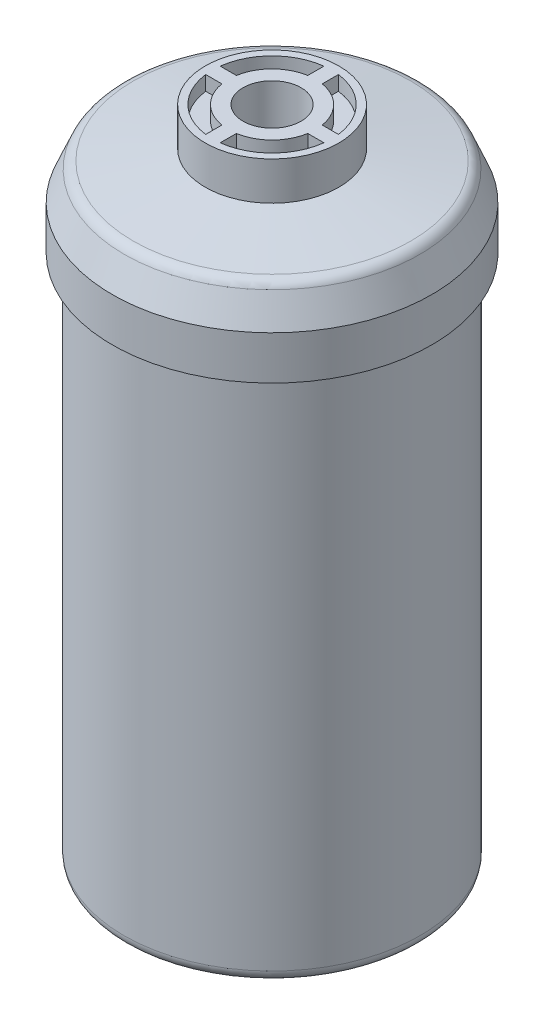
from build123d import *

# Parameters (mm, degrees)
CUT_EXTRUDE2_DEPTH = 3.175
CUT_EXTRUDE3_DEPTH = 3.175


with BuildPart() as part:
    # Sketch1 → Revolve1 (revolve)
    with BuildSketch(Plane.XY):
        with BuildLine():
            Line((6.35, 154.305), (14.605, 154.305))
            Line((14.605, 154.305), (14.605, 145.923))
            Line((14.605, 145.923), (30.329807741, 143.593398853))
            ThreePointArc((30.329807741, 143.593398853), (31.517982802, 143.084998901), (32.302189527, 142.057745136))
            Line((32.302189527, 142.057745136), (34.925, 135.763))
            Line((34.925, 135.763), (34.925, 126.238))
            Line((34.925, 126.238), (32.385, 124.968))
            Line((32.385, 124.968), (32.385, 13.12493032))
            ThreePointArc((32.385, 13.12493032), (31.763853046, 11.460717897), (30.204210245, 10.610458606))
            Line((30.204210245, 10.610458606), (14.605, 8.382))
            Line((14.605, 8.382), (14.605, 0))
            Line((14.605, 0), (6.35, 0))
            Line((6.35, 0), (6.35, 10.409948615))
            Line((6.35, 10.409948615), (29.21, 13.6756629))
            Line((29.21, 13.6756629), (29.21, 140.549643155))
            Line((29.21, 140.549643155), (6.35, 143.936309822))
            Line((6.35, 143.936309822), (6.35, 154.305))
        make_face()
    revolve(axis=Axis((0, 0, 0), (0, 1, 0)))

    # Sketch2 → Cut-Extrude2 (cut)
    with BuildSketch(Plane.XZ):
        with BuildLine():
            Line((1.5875, -12.920338618), (1.5875, -9.391776656))
            ThreePointArc((1.5875, -9.391776656), (6.735192091, -6.735192091), (9.391776656, -1.5875))
            Line((9.391776656, -1.5875), (12.920338618, -1.5875))
            ThreePointArc((12.920338618, -1.5875), (9.204762524, -9.204762524), (1.5875, -12.920338618))
        make_face()
        with BuildLine():
            Line((-1.5875, -12.920338618), (-1.5875, -9.391776656))
            ThreePointArc((-1.5875, -9.391776656), (-6.735192091, -6.735192091), (-9.391776656, -1.5875))
            Line((-9.391776656, -1.5875), (-12.920338618, -1.5875))
            ThreePointArc((-12.920338618, -1.5875), (-9.204762524, -9.204762524), (-1.5875, -12.920338618))
        make_face()
        with BuildLine():
            Line((-12.920338618, 1.5875), (-9.391776656, 1.5875))
            ThreePointArc((-9.391776656, 1.5875), (-6.735192091, 6.735192091), (-1.5875, 9.391776656))
            Line((-1.5875, 9.391776656), (-1.5875, 12.920338618))
            ThreePointArc((-1.5875, 12.920338618), (-9.204762524, 9.204762524), (-12.920338618, 1.5875))
        make_face()
        with BuildLine():
            Line((1.5875, 12.920338618), (1.5875, 9.391776656))
            ThreePointArc((1.5875, 9.391776656), (6.735192091, 6.735192091), (9.391776656, 1.5875))
            Line((9.391776656, 1.5875), (12.920338618, 1.5875))
            ThreePointArc((12.920338618, 1.5875), (9.204762524, 9.204762524), (1.5875, 12.920338618))
        make_face()
    extrude(amount=-CUT_EXTRUDE2_DEPTH, mode=Mode.SUBTRACT)

    # Sketch3 → Cut-Extrude3 (cut)
    with BuildSketch(Plane(origin=(0, 154.305, 0), x_dir=(-1, 0, 0), z_dir=(0, 1, 0))):
        with BuildLine():
            Line((1.5875, -12.920338618), (1.5875, -9.391776656))
            ThreePointArc((1.5875, -9.391776656), (6.735192091, -6.735192091), (9.391776656, -1.5875))
            Line((9.391776656, -1.5875), (12.920338618, -1.5875))
            ThreePointArc((12.920338618, -1.5875), (9.204762524, -9.204762524), (1.5875, -12.920338618))
        make_face()
        with BuildLine():
            Line((-1.5875, -12.920338618), (-1.5875, -9.391776656))
            ThreePointArc((-1.5875, -9.391776656), (-6.735192091, -6.735192091), (-9.391776656, -1.5875))
            Line((-9.391776656, -1.5875), (-12.920338618, -1.5875))
            ThreePointArc((-12.920338618, -1.5875), (-9.204762524, -9.204762524), (-1.5875, -12.920338618))
        make_face()
        with BuildLine():
            Line((-12.920338618, 1.5875), (-9.391776656, 1.5875))
            ThreePointArc((-9.391776656, 1.5875), (-6.735192091, 6.735192091), (-1.5875, 9.391776656))
            Line((-1.5875, 9.391776656), (-1.5875, 12.920338618))
            ThreePointArc((-1.5875, 12.920338618), (-9.204762524, 9.204762524), (-12.920338618, 1.5875))
        make_face()
        with BuildLine():
            Line((1.5875, 12.920338618), (1.5875, 9.391776656))
            ThreePointArc((1.5875, 9.391776656), (6.735192091, 6.735192091), (9.391776656, 1.5875))
            Line((9.391776656, 1.5875), (12.920338618, 1.5875))
            ThreePointArc((12.920338618, 1.5875), (9.204762524, 9.204762524), (1.5875, 12.920338618))
        make_face()
    extrude(amount=-CUT_EXTRUDE3_DEPTH, mode=Mode.SUBTRACT)


solid = part.part
